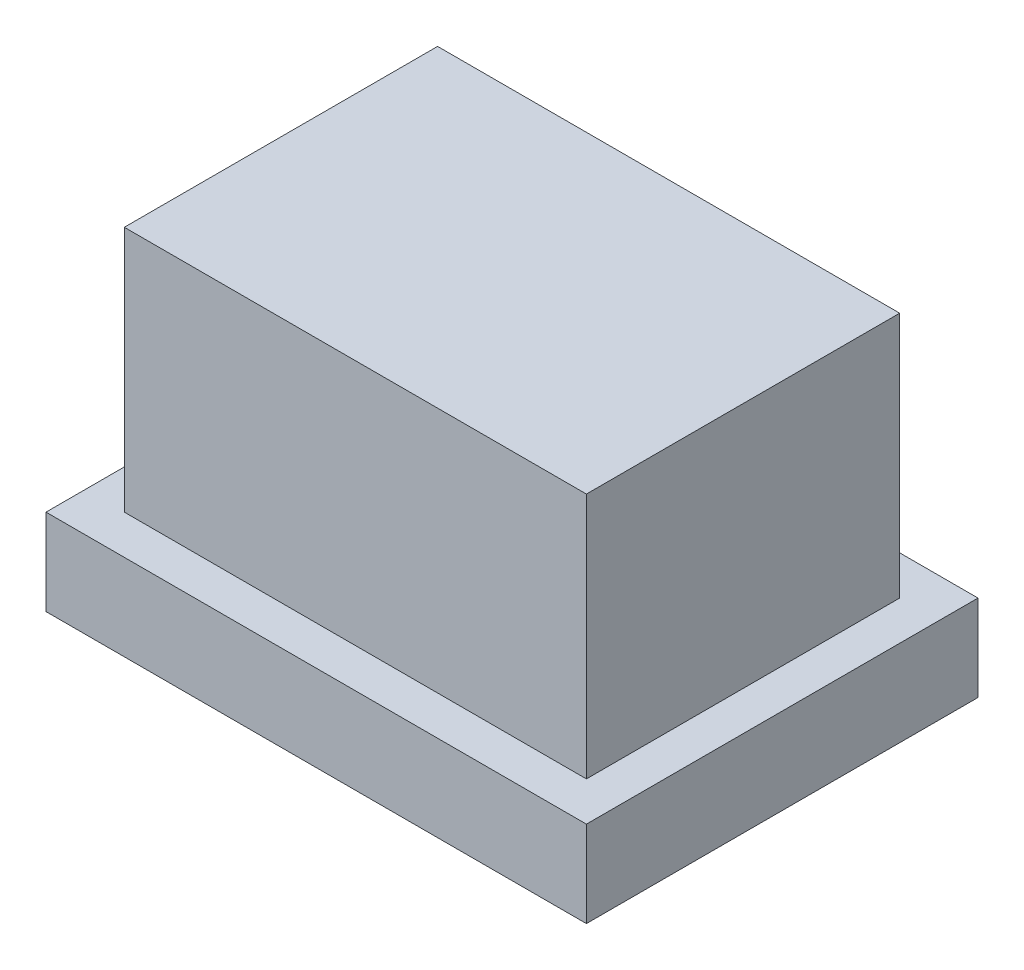
from build123d import *

# Parameters (mm, degrees)
CROQUIS2_W              = 13.8
CROQUIS2_H              = 10
SALIENTE_EXTRUIR1_DEPTH = 2.2
CROQUIS3_W              = 11.8
CROQUIS3_H              = 8
SALIENTE_EXTRUIR2_DEPTH = 6.3
CROQUIS4_R              = 3.5
CORTAR_EXTRUIR1_DEPTH   = 8


with BuildPart() as part:
    # Croquis2 → Saliente-Extruir1 (new body)
    with BuildSketch(Plane(origin=(0, 0, 0), x_dir=(1, 0, 0), z_dir=(0, 1, 0))):
        with Locations((-0.655307263, 0.782122905)):
            Rectangle(CROQUIS2_W, CROQUIS2_H)
    extrude(amount=SALIENTE_EXTRUIR1_DEPTH)

    # Croquis3 → Saliente-Extruir2 (add)
    with BuildSketch(Plane(origin=(0, 2.2, 0), x_dir=(1, 0, 0), z_dir=(0, 1, 0))):
        with Locations((-0.655307263, 0.782122905)):
            Rectangle(CROQUIS3_W, CROQUIS3_H)
    extrude(amount=SALIENTE_EXTRUIR2_DEPTH)

    # Croquis4 → Cortar-Extruir1 (cut)
    with BuildSketch(Plane.XZ):
        with Locations((-0.655307263, -0.782122905)):
            Circle(CROQUIS4_R)
    extrude(amount=-CORTAR_EXTRUIR1_DEPTH, mode=Mode.SUBTRACT)


solid = part.part
